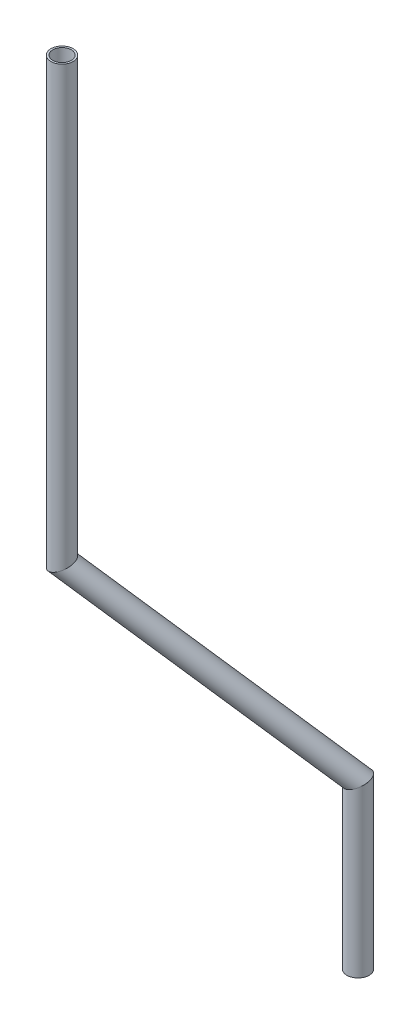
from build123d import *

# Parameters (mm, degrees)
SKETCH1_R                 = 6.35
SKETCH1_R_2               = 5.2832
PIPE_0_5_SCH_40_1_DEPTH   = 255.530329215
SKETCH1_ON_SEGMENT_2_R    = 6.35
SKETCH1_ON_SEGMENT_2_R_2  = 5.2832
PIPE_0_5_SCH_40_1_2_DEPTH = 168.045193957
SKETCH1_ON_SEGMENT_3_R    = 6.35
SKETCH1_ON_SEGMENT_3_R_2  = 5.2832
PIPE_0_5_SCH_40_1_3_DEPTH = 98.912631109


with BuildPart() as part:
    # Sketch1 → Pipe 0.5 SCH 40(1) (new body)
    with BuildSketch(Plane(origin=(-436.190807933, 824.623396558, 450.405195918), x_dir=(1, 0, 0), z_dir=(0, -1, 0))):
        Circle(SKETCH1_R)
        Circle(SKETCH1_R_2, mode=Mode.SUBTRACT)
    extrude(amount=PIPE_0_5_SCH_40_1_DEPTH)

    # Pipe 0.5 SCH 40(1) mitre 1
    split(bisect_by=Plane(origin=(-436.190807933, 574.211936593, 450.405195918), x_dir=(-0.946486903, -0.322742224, 0), z_dir=(-0.309943518, 0.908952901, 0.278818291)), keep=Keep.TOP)


with BuildPart() as body_2:
    # Sketch1 on segment 2 (carried to segment 2) → Pipe 0.5 SCH 40_1 2 (new body)
    with BuildSketch(Plane(origin=(-439.075025188, 577.551439556, 452.999773567), x_dir=(0.807870031, 0.56344812, 0.172835844), z_dir=(0.56344812, -0.652390753, -0.506865388))):
        Circle(SKETCH1_ON_SEGMENT_2_R)
        Circle(SKETCH1_ON_SEGMENT_2_R_2, mode=Mode.SUBTRACT)
    extrude(amount=PIPE_0_5_SCH_40_1_2_DEPTH)

    # Pipe 0.5 SCH 40_1 2 mitre 1
    split(bisect_by=Plane(origin=(-436.190807933, 574.211936593, 450.405195918), x_dir=(0.946486903, 0.322742224, 0), z_dir=(0.309943518, -0.908952901, -0.278818291)), keep=Keep.TOP)

    # Pipe 0.5 SCH 40_1 2 mitre 2
    split(bisect_by=Plane(origin=(-347.274493823, 471.259811951, 370.418058734), x_dir=(-0.946486903, -0.322742224, 0), z_dir=(-0.309943518, 0.908952901, 0.278818291)), keep=Keep.TOP)


with BuildPart() as body_3:
    # Sketch1 on segment 3 (carried to segment 3) → Pipe 0.5 SCH 40_1 3 (new body)
    with BuildSketch(Plane(origin=(-347.274493823, 476.378681201, 370.418058734), x_dir=(1, 0, 0), z_dir=(0, -1, 0))):
        Circle(SKETCH1_ON_SEGMENT_3_R)
        Circle(SKETCH1_ON_SEGMENT_3_R_2, mode=Mode.SUBTRACT)
    extrude(amount=PIPE_0_5_SCH_40_1_3_DEPTH)

    # Pipe 0.5 SCH 40_1 3 mitre 1
    split(bisect_by=Plane(origin=(-347.274493823, 471.259811951, 370.418058734), x_dir=(0.946486903, 0.322742224, 0), z_dir=(0.309943518, -0.908952901, -0.278818291)), keep=Keep.TOP)


solid = Compound([part.part, body_2.part, body_3.part])
